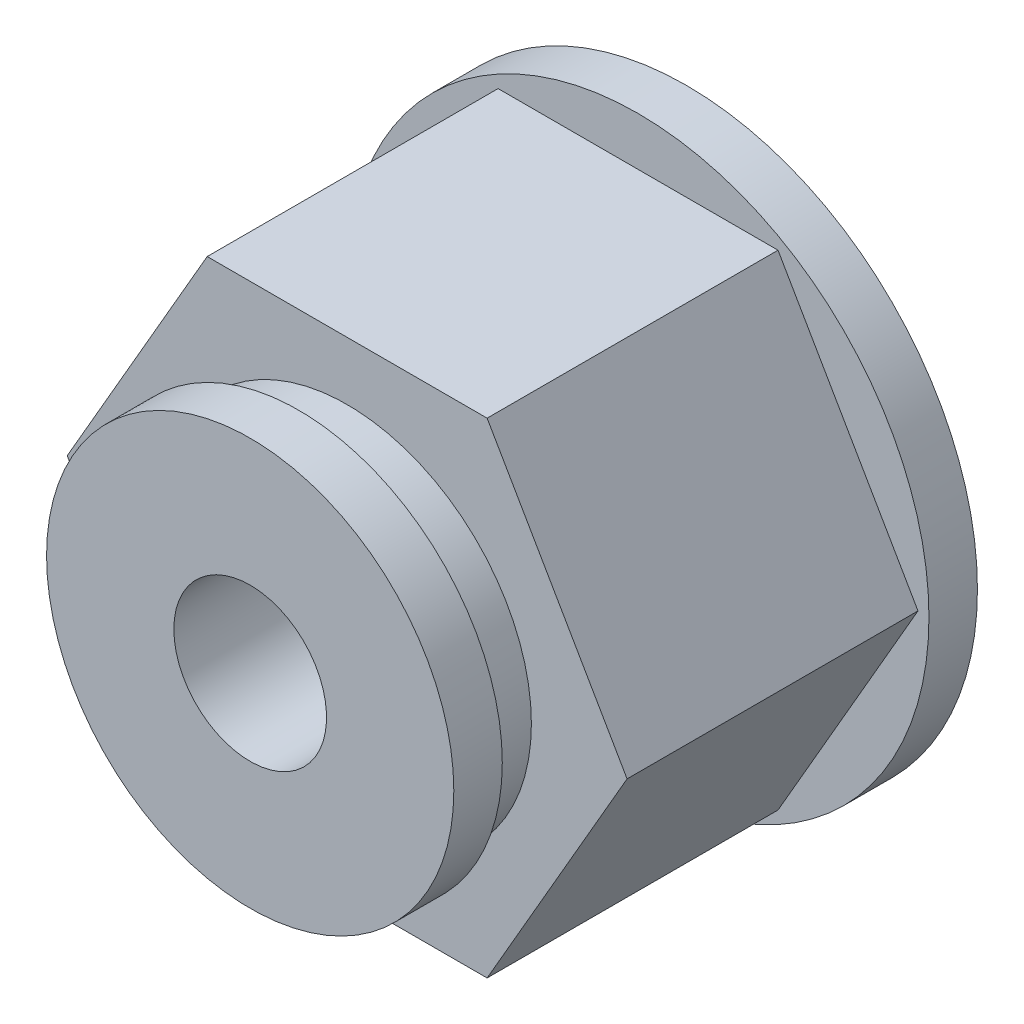
from build123d import *

# Parameters (mm, degrees)
BOSS_EXTRU_1_DEPTH      = 3.81
ESQUISSE2_R             = 7.62
BOSS_EXTRU_2_DEPTH      = 1.27
ESQUISSE3_R             = 4.826
BOSS_EXTRU_3_DEPTH      = 1.27
ESQUISSE4_R             = 5.334
BOSS_EXTRU_4_DEPTH      = 1.27
ESQUISSE5_R             = 2
ENL_V_MAT_EXTRU_1_DEPTH = 12.43


with BuildPart() as part:
    # Esquisse1 → Boss.-Extru.1 (new body, symmetric)
    with BuildSketch(Plane.XY):
        Polygon((7.332348419, 0), (3.666174209, 6.35), (-3.666174209, 6.35), (-7.332348419, 0), (-3.666174209, -6.35), (3.666174209, -6.35), align=None)
    extrude(amount=BOSS_EXTRU_1_DEPTH, both=True)

    # Esquisse2 → Boss.-Extru.2 (add)
    with BuildSketch(Plane(origin=(0, 0, -3.81), x_dir=(-1, 0, 0), z_dir=(0, 0, -1))):
        Circle(ESQUISSE2_R)
    extrude(amount=BOSS_EXTRU_2_DEPTH)

    # Esquisse3 → Boss.-Extru.3 (add)
    with BuildSketch(Plane.XY.offset(3.81)):
        Circle(ESQUISSE3_R)
    extrude(amount=BOSS_EXTRU_3_DEPTH)

    # Esquisse4 → Boss.-Extru.4 (add)
    with BuildSketch(Plane.XY.offset(5.08)):
        Circle(ESQUISSE4_R)
    extrude(amount=BOSS_EXTRU_4_DEPTH)

    # Esquisse5 → Enlèv. mat.-Extru.1 (cut, through all)
    with BuildSketch(Plane(origin=(0, 0, -5.08), x_dir=(-1, 0, 0), z_dir=(0, 0, -1))):
        Circle(ESQUISSE5_R)
    extrude(amount=-ENL_V_MAT_EXTRU_1_DEPTH, mode=Mode.SUBTRACT)


solid = part.part
